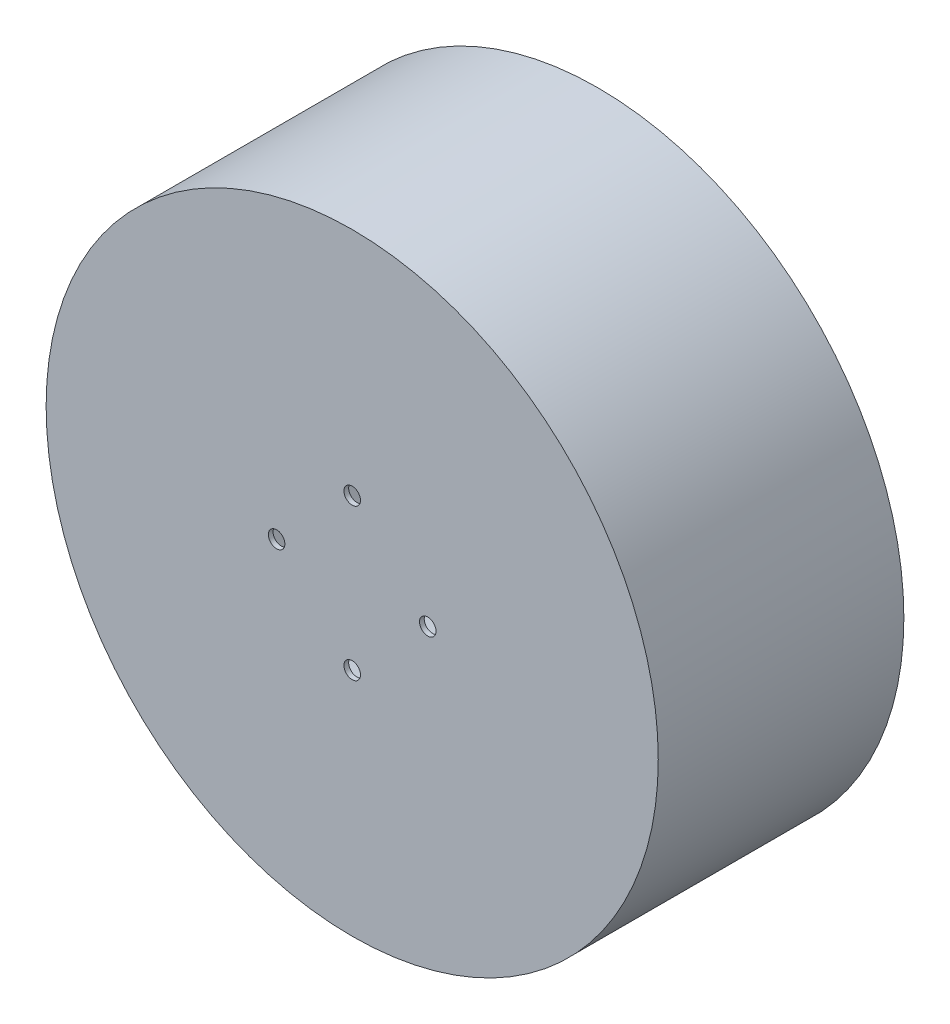
from build123d import *

# Parameters (mm, degrees)
SKETCH1_R           = 101.6
SKETCH1_R_2         = 5.55625
BOSS_EXTRUDE2_DEPTH = 3.175
SKETCH2_R           = 205.74
SKETCH2_R_2         = 101.6
BOSS_EXTRUDE3_DEPTH = 165.1


with BuildPart() as part:
    # Sketch1 → Boss-Extrude2 (new body)
    with BuildSketch(Plane.XY):
        Circle(SKETCH1_R)
        with Locations((0, 50.8)):
            Circle(SKETCH1_R_2, mode=Mode.SUBTRACT)
        with Locations((50.8, 0)):
            Circle(SKETCH1_R_2, mode=Mode.SUBTRACT)
        with Locations((0, -50.8)):
            Circle(SKETCH1_R_2, mode=Mode.SUBTRACT)
        with Locations((-50.8, 0)):
            Circle(SKETCH1_R_2, mode=Mode.SUBTRACT)
    extrude(amount=BOSS_EXTRUDE2_DEPTH)

    # Sketch2 → Boss-Extrude3 (add)
    with BuildSketch(Plane.XY.offset(3.175)):
        Circle(SKETCH2_R)
        Circle(SKETCH2_R_2, mode=Mode.SUBTRACT)
    extrude(amount=-BOSS_EXTRUDE3_DEPTH)


solid = part.part
